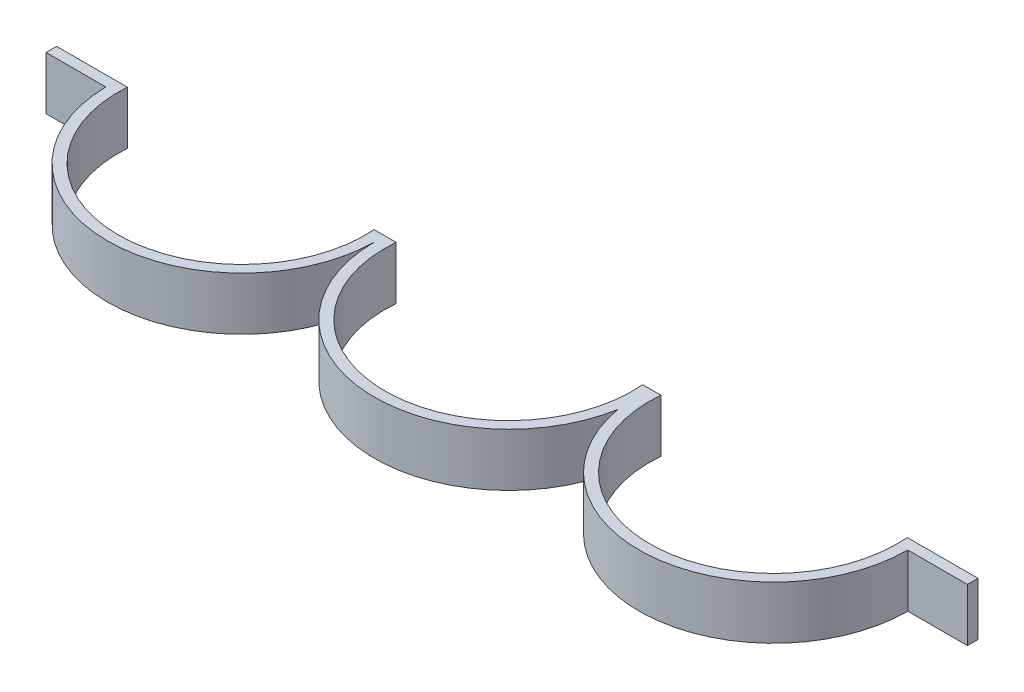
from build123d import *

# Parameters (mm, degrees)
EXTRUDE_1_DEPTH = 30


with BuildPart() as part:
    # 草图3 → 凸台-拉伸1 (new body)
    with BuildSketch(Plane(origin=(0, 0, 0), x_dir=(1, 0, 0), z_dir=(0, 1, 0))):
        with BuildLine():
            Line((-227.985581002, 0), (-261.817326429, 0))
            Line((-261.817326429, 0), (-261.817326429, 6))
            Line((-261.817326429, 6), (-221.817326429, 6))
            ThreePointArc((-221.817326429, 6), (-151.992790501, -68.953199218), (-82.168254573, 6))
            Line((-82.168254573, 6), (-69.742383097, 6))
            ThreePointArc((-69.742383097, 6), (0, -70), (69.742383097, 6))
            Line((69.742383097, 6), (80.018614475, 6))
            ThreePointArc((80.018614475, 6), (149.760997572, -70), (219.503380668, 6))
            Line((219.503380668, 6), (259.503380668, 6))
            Line((259.503380668, 6), (259.503380668, 0))
            Line((259.503380668, 0), (225.760997572, 0))
            ThreePointArc((225.760997572, 0), (156.283347312, -75.71960746), (74.880498786, -12.996572686))
            ThreePointArc((74.880498786, -12.996572686), (-6.52234974, -75.71960746), (-76, 0))
            ThreePointArc((-76, 0), (-151.992790501, -74.953199218), (-227.985581002, 0))
        make_face()
    extrude(amount=EXTRUDE_1_DEPTH)


solid = part.part
